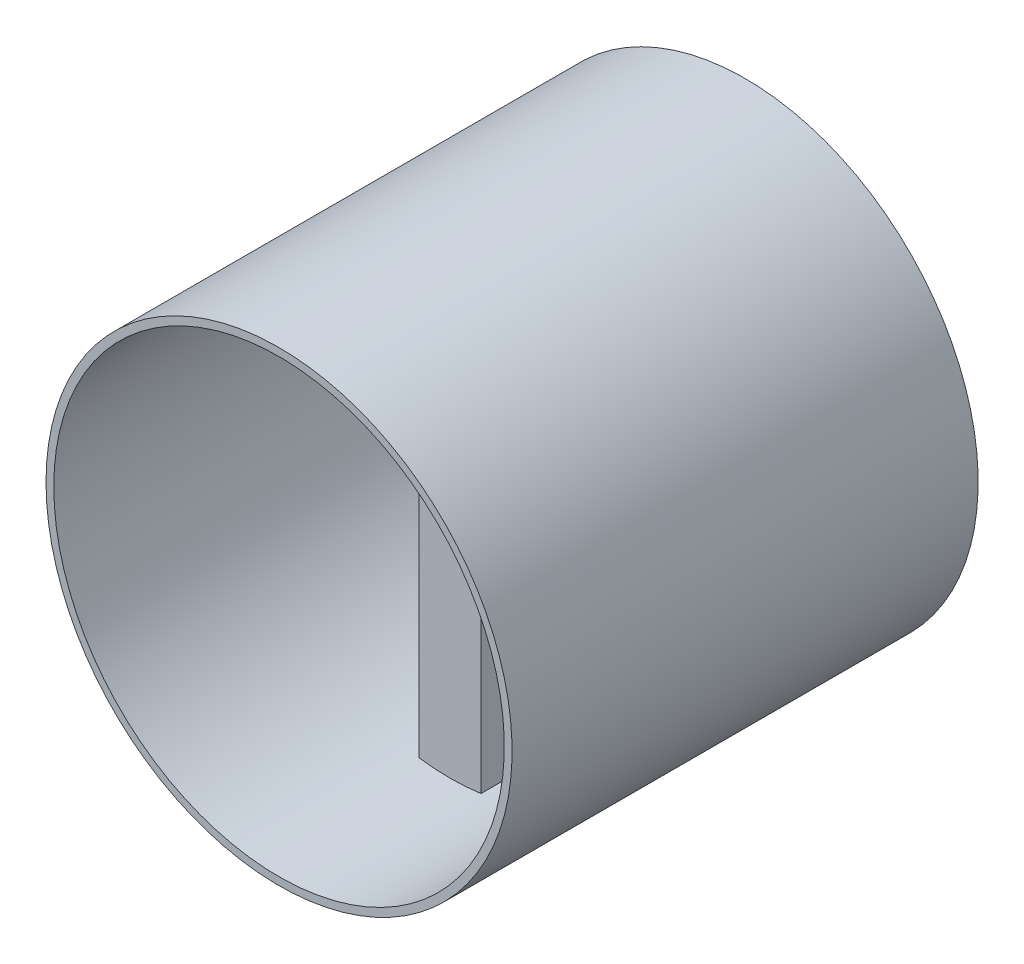
from build123d import *

# Parameters (mm, degrees)
ESQUISSE1_W             = 8
ESQUISSE1_H             = 59
BOSS_EXTRU_1_DEPTH      = 60
ESQUISSE3_R             = 30
ESQUISSE3_R_2           = 29
BOSS_EXTRU_2_DEPTH      = 60
ESQUISSE4_R             = 29
ENL_V_MAT_EXTRU_3_DEPTH = 30
ENL_V_MAT_EXTRU_5_DEPTH = 1.5
ESQUISSE6_R             = 29
ENL_V_MAT_EXTRU_6_DEPTH = 22
ESQUISSE7_R             = 2
ENL_V_MAT_EXTRU_7_DEPTH = 6.5
ESQUISSE9_R             = 0.5
ENL_V_MAT_EXTRU_8_DEPTH = 4


with BuildPart() as part:
    # Esquisse1 → Boss.-Extru.1 (new body)
    with BuildSketch(Plane.XY):
        with Locations((4, 29.5)):
            Rectangle(ESQUISSE1_W, ESQUISSE1_H)
    extrude(amount=BOSS_EXTRU_1_DEPTH)

    # Esquisse3 → Boss.-Extru.2 (add)
    with BuildSketch(Plane(origin=(0, 0, 0), x_dir=(-1, 0, 0), z_dir=(0, 0, -1))):
        with Locations((-4, 29.5)):
            Circle(ESQUISSE3_R)
        with Locations((-4, 29.5)):
            Circle(ESQUISSE3_R_2, mode=Mode.SUBTRACT)
    extrude(amount=-BOSS_EXTRU_2_DEPTH)

    # Esquisse4 → Enlèv. mat.-Extru.3 (cut)
    with BuildSketch(Plane(origin=(0, 0, 0), x_dir=(-1, 0, 0), z_dir=(0, 0, -1))):
        with Locations((-4, 29.5)):
            Circle(ESQUISSE4_R)
    extrude(amount=-ENL_V_MAT_EXTRU_3_DEPTH, mode=Mode.SUBTRACT)

    # Esquisse5 → Enlèv. mat.-Extru.5 (cut)
    with BuildSketch(Plane(origin=(0, 0, 30), x_dir=(-1, 0, 0), z_dir=(0, 0, -1))):
        with BuildLine():
            Line((-6, 43), (-6.967257844, 29.9420191))
            ThreePointArc((-6.967257844, 29.9420191), (-7, 29.5), (-6.967257844, 29.0579809))
            Line((-6.967257844, 29.0579809), (-6, 16))
            ThreePointArc((-6, 16), (-4, 14), (-2, 16))
            Line((-2, 16), (-1.032742156, 29.0579809))
            ThreePointArc((-1.032742156, 29.0579809), (-1, 29.5), (-1.032742156, 29.9420191))
            Line((-1.032742156, 29.9420191), (-2, 43))
            ThreePointArc((-2, 43), (-4, 45), (-6, 43))
        make_face()
    extrude(amount=-ENL_V_MAT_EXTRU_5_DEPTH, mode=Mode.SUBTRACT)

    # Esquisse6 → Enlèv. mat.-Extru.6 (cut)
    with BuildSketch(Plane.XY.offset(60)):
        with Locations((4, 29.5)):
            Circle(ESQUISSE6_R)
    extrude(amount=-ENL_V_MAT_EXTRU_6_DEPTH, mode=Mode.SUBTRACT)

    # Esquisse7 → Enlèv. mat.-Extru.7 (cut)
    with BuildSketch(Plane(origin=(0, 0, 31.5), x_dir=(-1, 0, 0), z_dir=(0, 0, -1))):
        with Locations((-4, 29.5)):
            Circle(ESQUISSE7_R)
    extrude(amount=-ENL_V_MAT_EXTRU_7_DEPTH, mode=Mode.SUBTRACT)

    # Esquisse9 → Enlèv. mat.-Extru.8 (cut)
    with BuildSketch(Plane(origin=(0, 0, 31.5), x_dir=(-1, 0, 0), z_dir=(0, 0, -1))):
        with Locations((-4, 43)):
            Circle(ESQUISSE9_R)
        with Locations((-4, 16)):
            Circle(ESQUISSE9_R)
    extrude(amount=-ENL_V_MAT_EXTRU_8_DEPTH, mode=Mode.SUBTRACT)


solid = part.part
